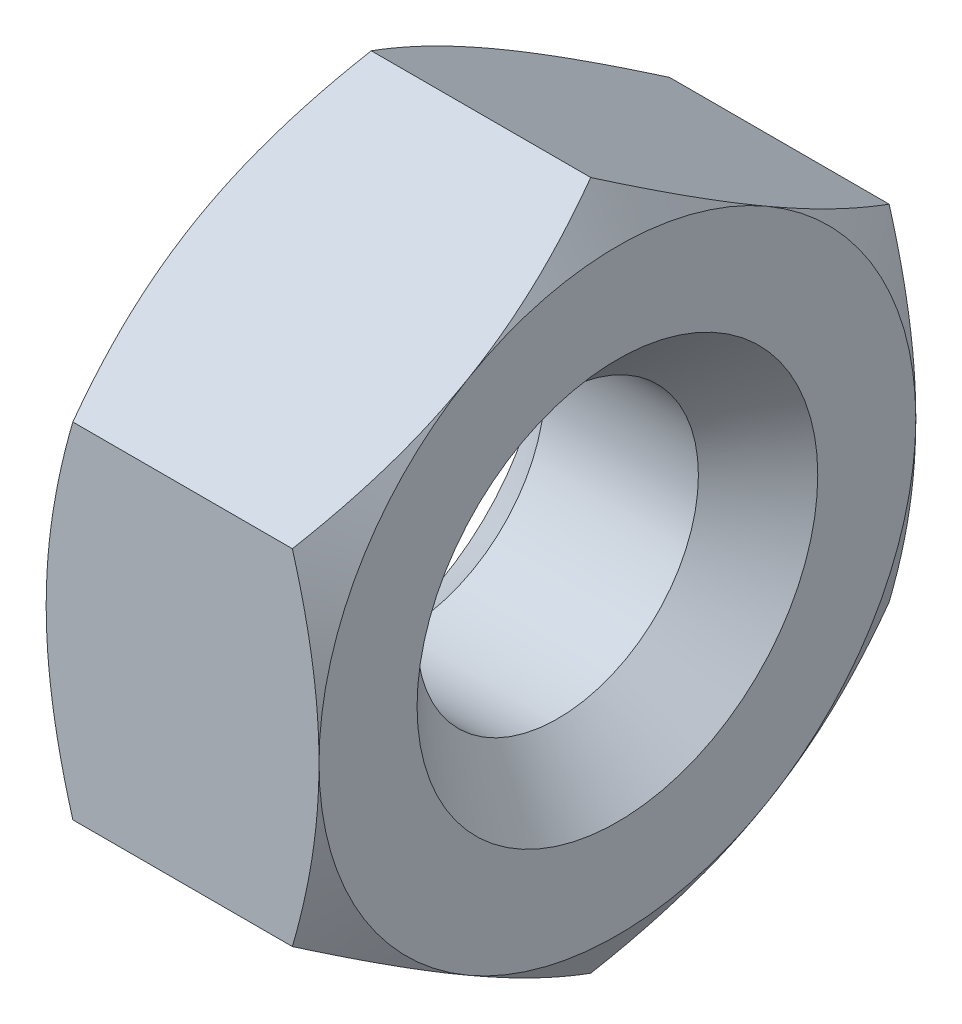
from build123d import *

# Parameters (mm, degrees)
EXTRUDE_M_DEPTH     = 1.6
HOLE_WIZARD_D_D     = 3.3
HOLE_WIZARD_D_DEPTH = 3.2
CHAMFER1_SIZE       = 0.7


with BuildPart() as part:
    # Sketch1 → Extrude m (new body, symmetric)
    with BuildSketch(Plane(origin=(0, 0, 0), x_dir=(0, 0, -1), z_dir=(1, 0, 0))):
        Polygon((0, 4.041451884), (-3.5, 2.020725942), (-3.5, -2.020725942), (0, -4.041451884), (3.5, -2.020725942), (3.5, 2.020725942), align=None)
    extrude(amount=EXTRUDE_M_DEPTH, both=True)

    # Sketch2 → Cut-Revolve1 (revolve, cut)
    with BuildSketch(Plane.XY):
        Polygon((1.6, 4.041451884), (1.287392609, 4.041451884), (1.6, 3.5), align=None)
        Polygon((-1.6, 4.041451884), (-1.6, 3.5), (-1.287392609, 4.041451884), align=None)
    revolve(axis=Axis((0, 0, 0), (1, 0, 0)), mode=Mode.SUBTRACT)

    # Hole Wizard d
    with Locations(Plane(origin=(1.6, 0, 0), x_dir=(0, 0, -1), z_dir=(1, 0, 0))):
        with Locations((0, 0)):
            Hole(HOLE_WIZARD_D_D / 2, depth=HOLE_WIZARD_D_DEPTH)

    # Chamfer1
    chamfer1_edges = [part.edges().sort_by_distance(p)[0] for p in [
        (1.6, 0, -1.65),
        (-1.6, 0, -1.65),
    ]]
    chamfer(chamfer1_edges, length=CHAMFER1_SIZE)


solid = part.part
